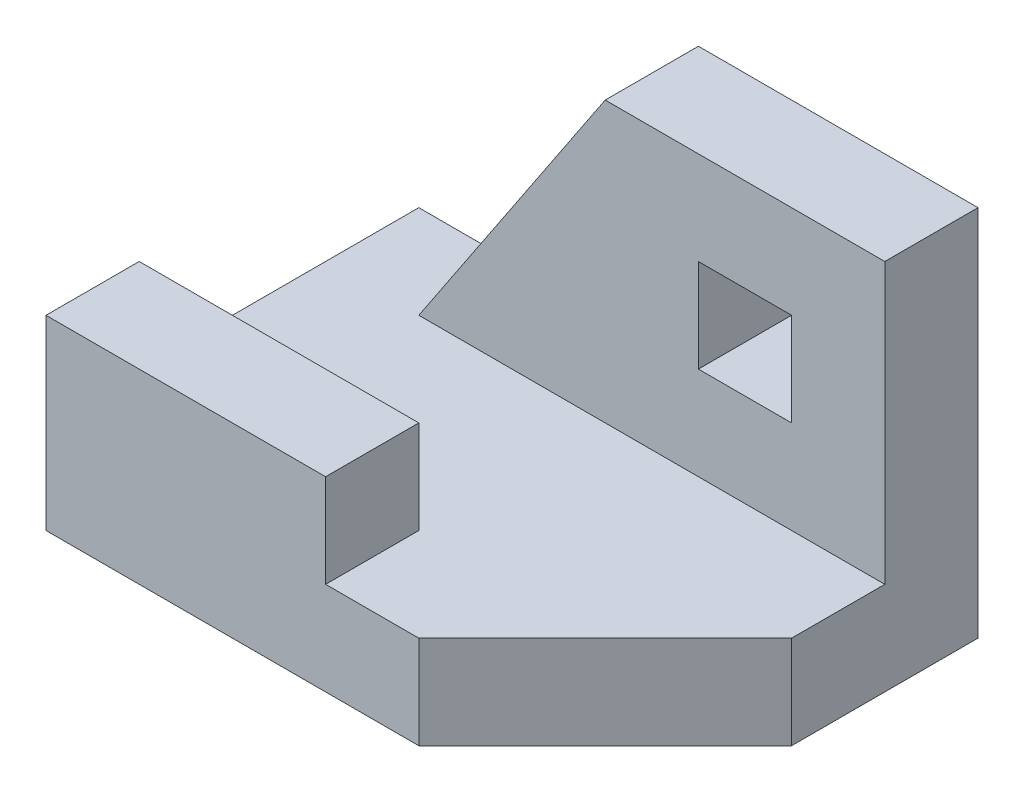
from build123d import *

# Parameters (mm, degrees)
BOSS_EXTRUDE1_DEPTH = 254
SKETCH1_3_W         = 762
SKETCH1_3_H         = 254
BOSS_EXTRUDE2_DEPTH = 508
SKETCH1_4_W         = 1270
SKETCH1_4_H         = 254
BOSS_EXTRUDE3_DEPTH = 1016
SKETCH2_W           = 254
SKETCH2_H           = 254
CUT_EXTRUDE1_DEPTH  = 254


with BuildPart() as part:
    # Sketch1 → Boss-Extrude1 (new body)
    with BuildSketch(Plane(origin=(0, 0, 0), x_dir=(1, 0, 0), z_dir=(0, 1, 0))):
        Polygon((0, 1016), (0, 254), (762, 254), (762, 0), (1016, 0), (1524, 508), (1524, 762), (254, 762), (254, 1016), align=None)
    extrude(amount=BOSS_EXTRUDE1_DEPTH)

    # Sketch1_3 → Boss-Extrude2 (add)
    with BuildSketch(Plane(origin=(0, 0, 0), x_dir=(1, 0, 0), z_dir=(0, 1, 0))):
        with Locations((381, 127)):
            Rectangle(SKETCH1_3_W, SKETCH1_3_H)
    extrude(amount=BOSS_EXTRUDE2_DEPTH)

    # Sketch1_4 → Boss-Extrude3 (add)
    with BuildSketch(Plane(origin=(0, 0, 0), x_dir=(1, 0, 0), z_dir=(0, 1, 0))):
        with Locations((889, 889)):
            Rectangle(SKETCH1_4_W, SKETCH1_4_H)
    extrude(amount=BOSS_EXTRUDE3_DEPTH)

    # Sketch2 → Cut-Extrude1 (cut)
    with BuildSketch(Plane.XY.offset(-762)):
        Polygon((254, 254), (762, 1016), (254, 1016), align=None)
        with Locations((1143, 635)):
            Rectangle(SKETCH2_W, SKETCH2_H)
    extrude(amount=-CUT_EXTRUDE1_DEPTH, mode=Mode.SUBTRACT)


solid = part.part
